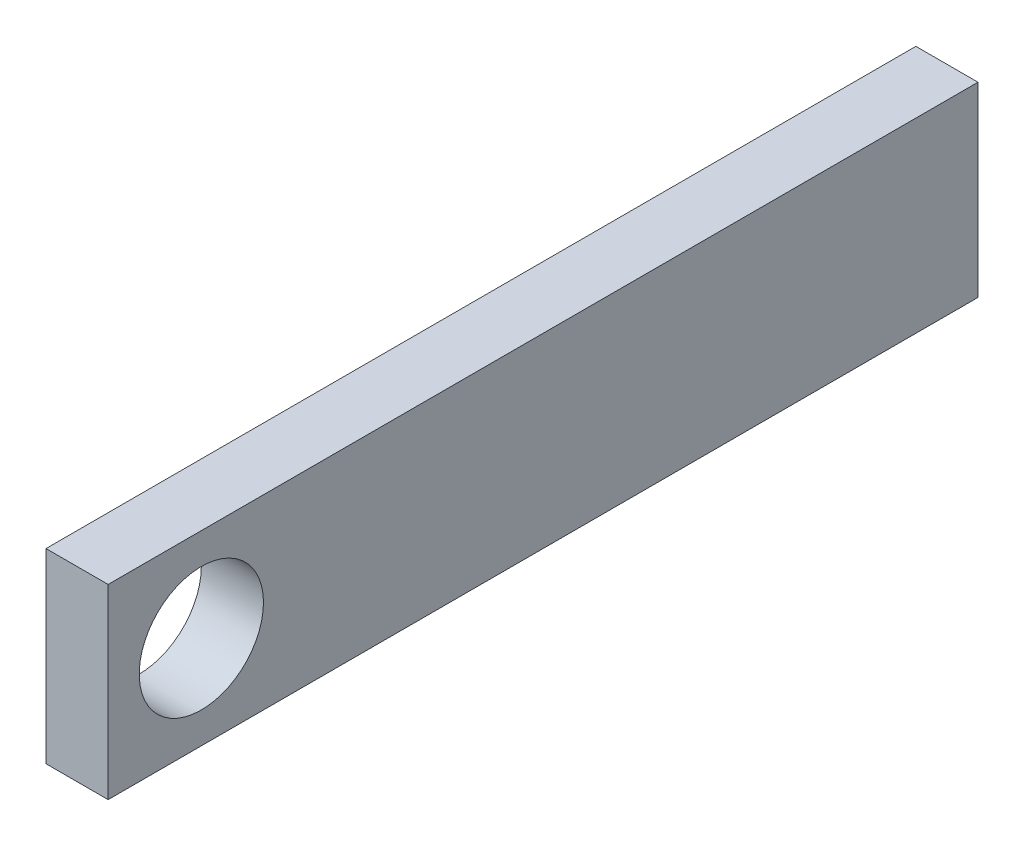
from build123d import *

# Parameters (mm, degrees)
SKETCH1_W           = 140
SKETCH1_H           = 30
SKETCH1_R           = 10
BOSS_EXTRUDE1_DEPTH = 10


with BuildPart() as part:
    # Sketch1 → Boss-Extrude1 (new body)
    with BuildSketch(Plane(origin=(0, 0, 0), x_dir=(0, 0, -1), z_dir=(1, 0, 0))):
        with Locations((55, 0)):
            Rectangle(SKETCH1_W, SKETCH1_H)
        Circle(SKETCH1_R, mode=Mode.SUBTRACT)
    extrude(amount=BOSS_EXTRUDE1_DEPTH)


solid = part.part
